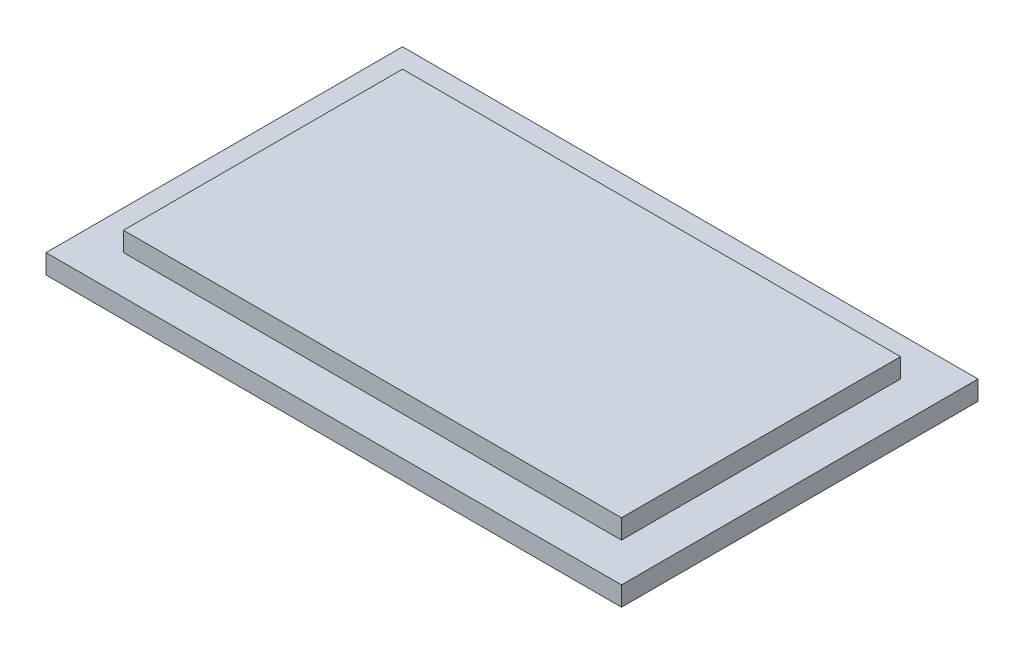
from build123d import *

# Parameters (mm, degrees)
SKETCH1_W           = 29.7
SKETCH1_H           = 18.4
BOSS_EXTRUDE1_DEPTH = 1
SKETCH1_3_W         = 25.7
SKETCH1_3_H         = 14.4
BOSS_EXTRUDE2_DEPTH = 1


with BuildPart() as part:
    # Sketch1 → Boss-Extrude1 (new body)
    with BuildSketch(Plane(origin=(0, 0, 0), x_dir=(1, 0, 0), z_dir=(0, 1, 0))):
        with Locations((-3.58847677, -6.251994981)):
            Rectangle(SKETCH1_W, SKETCH1_H)
    extrude(amount=-BOSS_EXTRUDE1_DEPTH)

    # Sketch1_3 → Boss-Extrude2 (add)
    with BuildSketch(Plane(origin=(0, 0, 0), x_dir=(1, 0, 0), z_dir=(0, 1, 0))):
        with Locations((-3.58847677, -6.251994981)):
            Rectangle(SKETCH1_3_W, SKETCH1_3_H)
    extrude(amount=BOSS_EXTRUDE2_DEPTH)


solid = part.part
